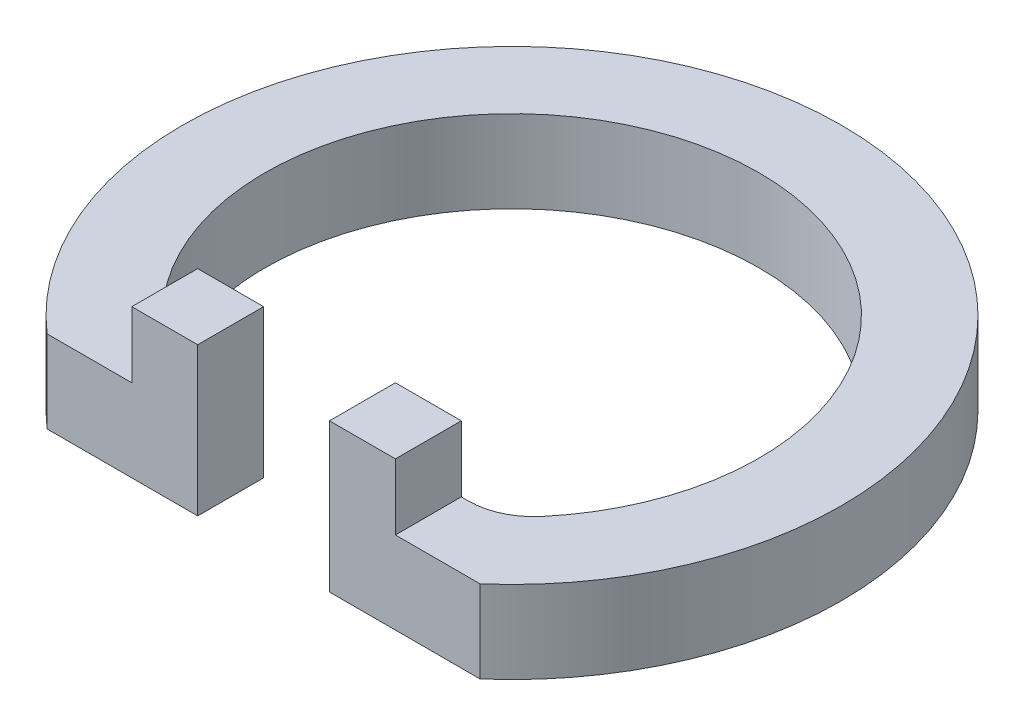
from build123d import *

# Parameters (mm, degrees)
SKETCH1_R           = 50.8
BOSS_EXTRUDE1_DEPTH = 12.7
CUT_EXTRUDE1_DEPTH  = 12.7
SKETCH3_W           = 10.16
SKETCH3_H           = 10.16
BOSS_EXTRUDE2_DEPTH = 10.16
FILLET1_R           = 10.16
FILLET2_R           = 10.16


with BuildPart() as part:
    # Sketch1 → Boss-Extrude1 (new body)
    with BuildSketch(Plane(origin=(0, 0, 0), x_dir=(1, 0, 0), z_dir=(0, 1, 0))):
        Circle(SKETCH1_R)
    extrude(amount=BOSS_EXTRUDE1_DEPTH)

    # Sketch2 → Cut-Extrude1 (cut)
    with BuildSketch(Plane(origin=(0, 12.7, 0), x_dir=(1, 0, 0), z_dir=(0, 1, 0))):
        with BuildLine():
            Line((-25.689206411, -28.136713987), (-10.16, -28.136713987))
            Line((-10.16, -28.136713987), (-10.16, -38.296713987))
            Line((-10.16, -38.296713987), (-33.376663971, -38.296713987))
            ThreePointArc((-33.376663971, -38.296713987), (0, -50.8), (33.376663971, -38.296713987))
            Line((33.376663971, -38.296713987), (10.16, -38.296713987))
            Line((10.16, -38.296713987), (10.16, -28.136713987))
            Line((10.16, -28.136713987), (25.689206411, -28.136713987))
            ThreePointArc((25.689206411, -28.136713987), (0, 38.1), (-25.689206411, -28.136713987))
        make_face()
    extrude(amount=-CUT_EXTRUDE1_DEPTH, mode=Mode.SUBTRACT)

    # Sketch3 → Boss-Extrude2 (add)
    with BuildSketch(Plane(origin=(-12.7, 12.7, 0), x_dir=(0, 0, -1), z_dir=(0, -1, 0))):
        with Locations((-33.216713987, -2.54)):
            Rectangle(SKETCH3_W, SKETCH3_H)
    boss_extrude2 = extrude(amount=-BOSS_EXTRUDE2_DEPTH)

    # Fillet1
    fillet1_edges = [part.edges().sort_by_distance(p)[0] for p in [
        (-25.689206411, 6.35, 28.136713987),
    ]]
    fillet(fillet1_edges, radius=FILLET1_R)

    # Mirror1: Boss-Extrude2 across plane
    add(boss_extrude2.mirror(Plane(origin=(0, 0, 0), x_dir=(0, 0, 1), z_dir=(1, 0, 0))))

    # Fillet2
    fillet2_edges = [part.edges().sort_by_distance(p)[0] for p in [
        (25.689206411, 6.35, 28.136713987),
    ]]
    fillet(fillet2_edges, radius=FILLET2_R)


solid = part.part
